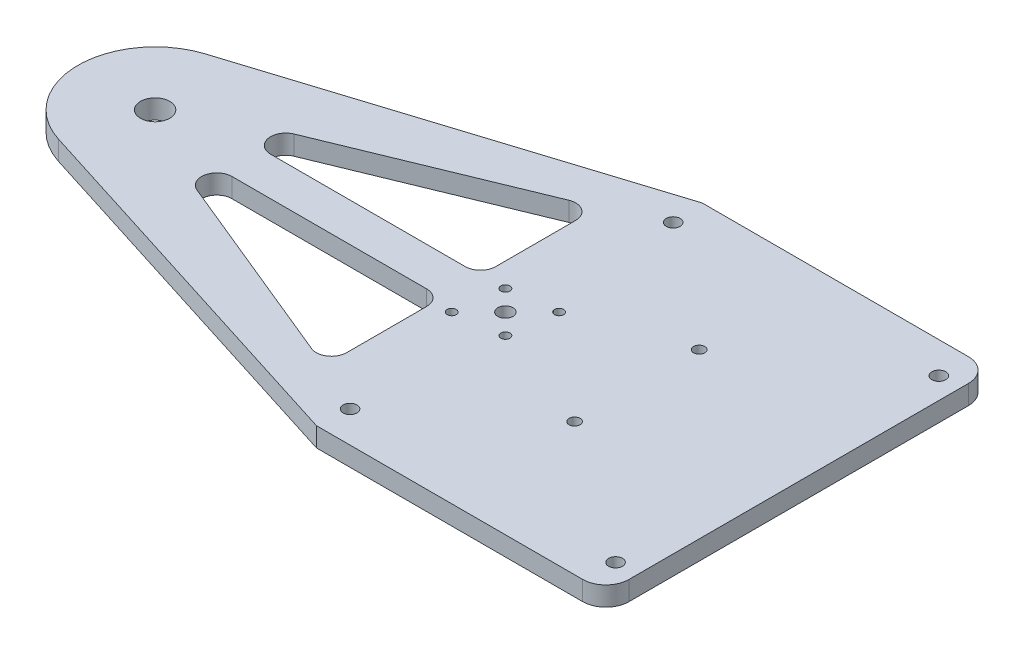
from build123d import *

# Parameters (mm, degrees)
SKETCH1_W           = 95.25
SKETCH1_H           = 127
BOSS_EXTRUDE1_DEPTH = 6.35
BOSS_EXTRUDE3_DEPTH = 6.35
SKETCH5_R           = 4.826
SKETCH5_R_2         = 2.5
SKETCH5_R_3         = 1.5
CUT_EXTRUDE1_DEPTH  = 7.35
CUT_EXTRUDE2_DEPTH  = 7.35
FILLET9_R           = 5
FILLET10_R          = 7.62
SKETCH7_R           = 2.2812375
CUT_EXTRUDE3_DEPTH  = 7.35
SKETCH8_R           = 1.830008083
CUT_EXTRUDE4_DEPTH  = 7.35


with BuildPart() as part:
    # Sketch1 → Boss-Extrude1 (new body)
    with BuildSketch(Plane(origin=(0, 0, 0), x_dir=(1, 0, 0), z_dir=(0, 1, 0))):
        Rectangle(SKETCH1_W, SKETCH1_H)
    extrude(amount=BOSS_EXTRUDE1_DEPTH)

    # Sketch4 → Boss-Extrude3 (add)
    with BuildSketch(Plane(origin=(0, 6.35, 0), x_dir=(1, 0, 0), z_dir=(0, 1, 0))):
        with BuildLine():
            Line((-47.625, 63.5), (-171.916018217, 24.219268021))
            ThreePointArc((-171.916018217, 24.219268021), (-189.6618, 0), (-171.916018217, -24.219268021))
            Line((-171.916018217, -24.219268021), (-47.625, -63.5))
            Line((-47.625, -63.5), (-47.625, 63.5))
        make_face()
    extrude(amount=-BOSS_EXTRUDE3_DEPTH)

    # Sketch5 → Cut-Extrude1 (cut, through all)
    with BuildSketch(Plane(origin=(0, 6.35, 0), x_dir=(1, 0, 0), z_dir=(0, 1, 0))):
        with Locations((-164.2618, 0)):
            Circle(SKETCH5_R)
        with Locations((-48.9458, 0)):
            Circle(SKETCH5_R_2)
        with Locations((-40.106965235, 8.838834765)):
            Circle(SKETCH5_R_3)
        with Locations((-57.784634765, -8.838834765)):
            Circle(SKETCH5_R_3)
        with Locations((-55.663314421, 6.717514421)):
            Circle(SKETCH5_R_3)
        with Locations((-42.228285579, -6.717514421)):
            Circle(SKETCH5_R_3)
    extrude(amount=-CUT_EXTRUDE1_DEPTH, mode=Mode.SUBTRACT)

    # Sketch6 → Cut-Extrude2 (cut, through all)
    with BuildSketch(Plane(origin=(0, 6.35, 0), x_dir=(1, 0, 0), z_dir=(0, 1, 0))):
        Polygon((-63.5, 45.163743355), (-157.9118, 6.35), (-63.5, 6.35), align=None)
        Polygon((-63.5, -6.35), (-63.5, -45.163743355), (-157.9118, -6.35), align=None)
    extrude(amount=-CUT_EXTRUDE2_DEPTH, mode=Mode.SUBTRACT)

    # Fillet9
    fillet9_edges = [part.edges().sort_by_distance(p)[0] for p in [
        (-63.5, 3.175, -45.163743355),
        (-63.5, 3.175, -6.35),
        (-157.9118, 3.175, -6.35),
        (-157.9118, 3.175, 6.35),
        (-63.5, 3.175, 6.35),
        (-63.5, 3.175, 45.163743355),
    ]]
    fillet(fillet9_edges, radius=FILLET9_R)

    # Fillet10
    fillet10_edges = [part.edges().sort_by_distance(p)[0] for p in [
        (47.625, 3.175, 63.5),
        (47.625, 3.175, -63.5),
    ]]
    fillet(fillet10_edges, radius=FILLET10_R)

    # Sketch7 → Cut-Extrude3 (cut, through all)
    with BuildSketch(Plane(origin=(0, 6.35, 0), x_dir=(1, 0, 0), z_dir=(0, 1, 0))):
        with Locations((-46.889614099, -53.200246229)):
            Circle(SKETCH7_R)
        with Locations((-46.889614099, 53.180131976)):
            Circle(SKETCH7_R)
        with Locations((40.557033552, 53.190189103)):
            Circle(SKETCH7_R)
        with Locations((40.539614099, -53.220360481)):
            Circle(SKETCH7_R)
    extrude(amount=-CUT_EXTRUDE3_DEPTH, mode=Mode.SUBTRACT)

    # Sketch8 → Cut-Extrude4 (cut, through all)
    with BuildSketch(Plane(origin=(0, 6.35, 0), x_dir=(1, 0, 0), z_dir=(0, 1, 0))):
        with Locations((-6.328465047, -19.828924843)):
            Circle(SKETCH8_R)
        with Locations((-6.328338046, 21.171490961)):
            Circle(SKETCH8_R)
    extrude(amount=-CUT_EXTRUDE4_DEPTH, mode=Mode.SUBTRACT)


solid = part.part
